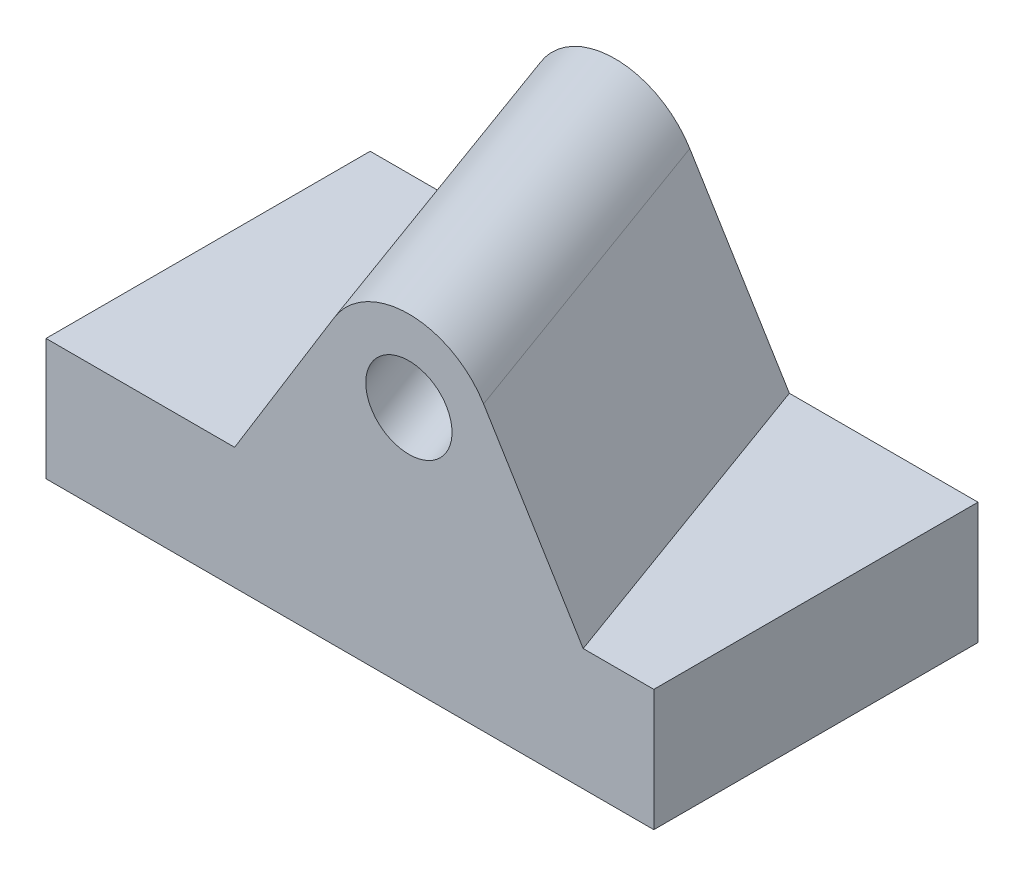
from build123d import *

# Parameters (mm, degrees)
SKETCH1_W                       = 150
SKETCH1_H                       = 30
BOSS_EXTRUDE1_DEPTH             = 80
BOSS_EXTRUDE4_REACH             = 144.711
SKETCH3_R                       = 10
BOSS_EXTRUDE4_DIRECTION_2_REACH = 144.711


with BuildPart() as part:
    # Sketch1 → Boss-Extrude1 (new body)
    with BuildSketch(Plane.XY):
        with Locations((0, 15)):
            Rectangle(SKETCH1_W, SKETCH1_H)
    extrude(amount=BOSS_EXTRUDE1_DEPTH)

    # Boss-Extrude4: up to this plane
    boss_extrude4_end = Plane(origin=(0, 0, 80), z_dir=(0, 0, 1))
    # Sketch3 → Boss-Extrude4 (add, up to the surface)
    with BuildSketch(Plane(origin=(12.855752194, 0, 35.320888862), x_dir=(0, 1, 0), z_dir=(0.34202014332566943, 0, 0.9396926207859081)), mode=Mode.PRIVATE) as boss_extrude4_sk1:
        with BuildLine():
            Line((30, -26.73371311), (70, -3.639702343))
            ThreePointArc((70, -3.639702343), (80, 13.680805733), (70, 31.001313809))
            Line((70, 31.001313809), (30, 54.095324576))
            Line((30, 54.095324576), (30, -26.73371311))
        make_face()
        with Locations((60, 13.680805733)):
            Circle(SKETCH3_R, mode=Mode.SUBTRACT)
    boss_extrude4_tool1 = split(extrude(boss_extrude4_sk1.sketch, amount=BOSS_EXTRUDE4_REACH, mode=Mode.PRIVATE), bisect_by=boss_extrude4_end, keep=Keep.BOTH, mode=Mode.PRIVATE)
    add(boss_extrude4_tool1.solids().sort_by_distance((0, 48.492065, 40))[0])

    # Boss-Extrude4 direction 2: up to this plane
    boss_extrude4_direction_2_end = Plane(origin=(0, 0, 0), z_dir=(0, 0, 1))
    # Sketch3 → Boss-Extrude4 direction 2 (add, up to the surface)
    with BuildSketch(Plane(origin=(12.855752194, 0, 35.320888862), x_dir=(0, 1, 0), z_dir=(0.34202014332566943, 0, 0.9396926207859081)), mode=Mode.PRIVATE) as boss_extrude4_direction_2_sk1:
        with BuildLine():
            Line((30, -26.73371311), (70, -3.639702343))
            ThreePointArc((70, -3.639702343), (80, 13.680805733), (70, 31.001313809))
            Line((70, 31.001313809), (30, 54.095324576))
            Line((30, 54.095324576), (30, -26.73371311))
        make_face()
        with Locations((60, 13.680805733)):
            Circle(SKETCH3_R, mode=Mode.SUBTRACT)
    boss_extrude4_direction_2_tool1 = split(extrude(boss_extrude4_direction_2_sk1.sketch, amount=-BOSS_EXTRUDE4_DIRECTION_2_REACH, mode=Mode.PRIVATE), bisect_by=boss_extrude4_direction_2_end, keep=Keep.BOTH, mode=Mode.PRIVATE)
    add(boss_extrude4_direction_2_tool1.solids().sort_by_distance((0, 48.492065, 40))[0])


solid = part.part
